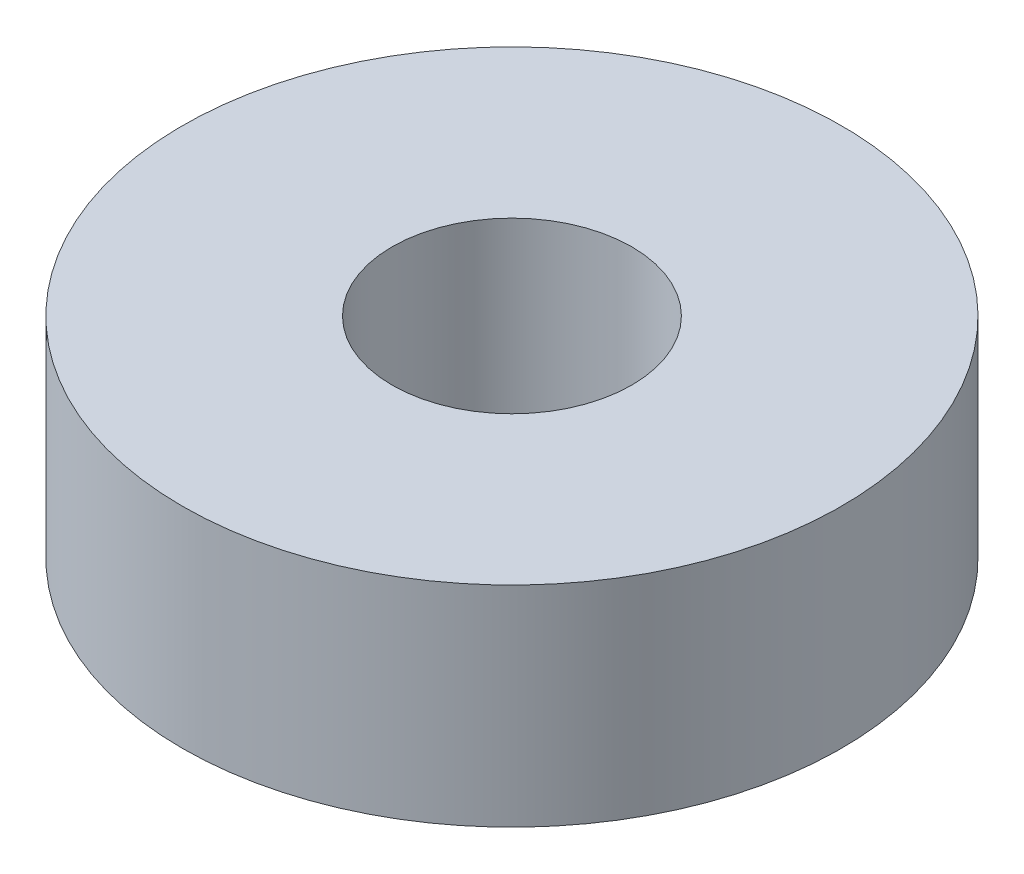
from build123d import *

# Parameters (mm, degrees)
SKETCH5_R           = 11
BOSS_EXTRUDE2_DEPTH = 7
SKETCH6_R           = 4
CUT_EXTRUDE3_DEPTH  = 8


with BuildPart() as part:
    # Sketch5 → Boss-Extrude2 (new body)
    with BuildSketch(Plane(origin=(0, 0, 0), x_dir=(1, 0, 0), z_dir=(0, 1, 0))):
        Circle(SKETCH5_R)
    extrude(amount=BOSS_EXTRUDE2_DEPTH)

    # Sketch6 → Cut-Extrude3 (cut)
    with BuildSketch(Plane(origin=(0, 7, 0), x_dir=(1, 0, 0), z_dir=(0, 1, 0))):
        Circle(SKETCH6_R)
    extrude(amount=-CUT_EXTRUDE3_DEPTH, mode=Mode.SUBTRACT)


solid = part.part
